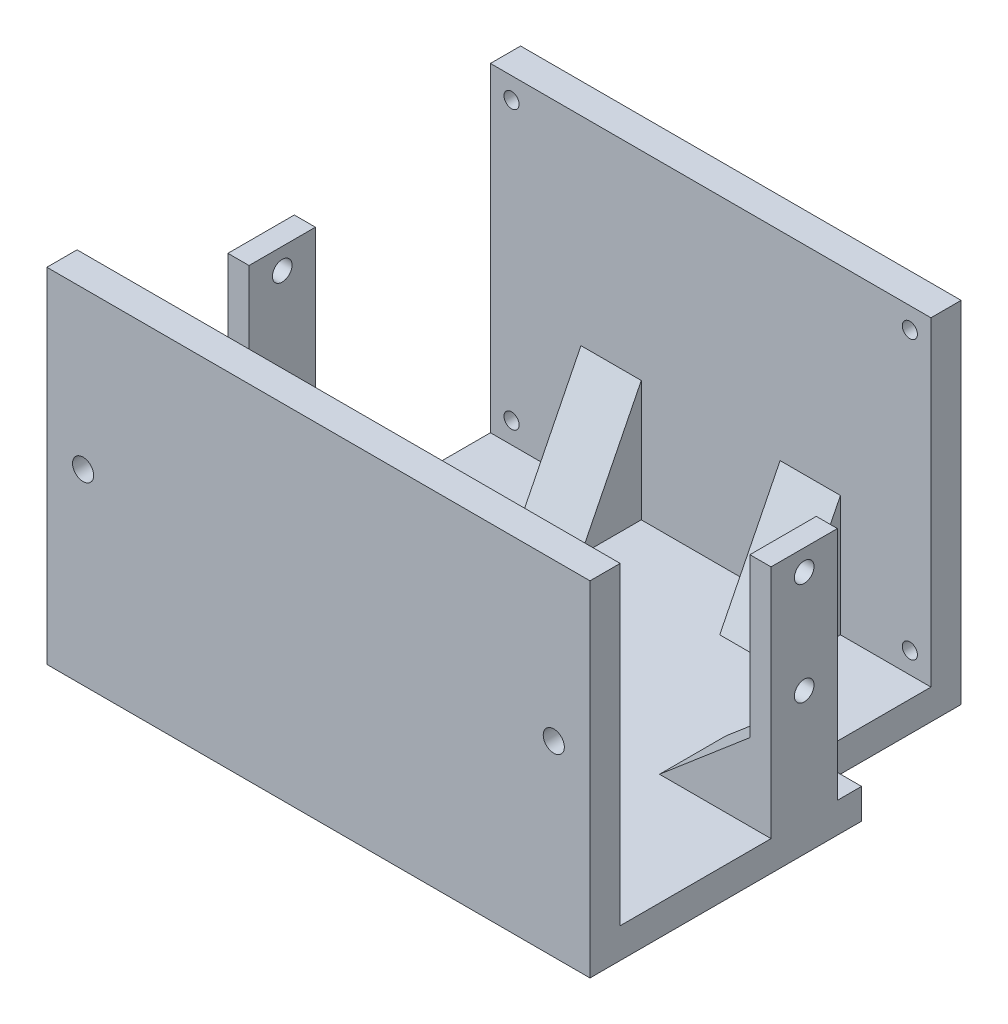
from build123d import *

# Parameters (mm, degrees)
ESTRUSIONE_ESTRUSIONE1_DEPTH = 5
SCHIZZO2_W                   = 73
SCHIZZO2_H                   = 5
ESTRUSIONE_ESTRUSIONE2_DEPTH = 53
SCHIZZO4_R                   = 1.25
TAGLIO_ESTRUSIONE1_DEPTH     = 10
SCHIZZO1_3_W                 = 3.5
SCHIZZO1_3_H                 = 11
ESTRUSIONE_ESTRUSIONE3_DEPTH = 44
SCHIZZO5_R                   = 1.625
TAGLIO_ESTRUSIONE2_DEPTH     = 113.645461515
SCHIZZO2_3_W                 = 90
SCHIZZO2_3_H                 = 5
ESTRUSIONE_ESTRUSIONE4_DEPTH = 52
SCHIZZO8_R                   = 1.75
TAGLIO_ESTRUSIONE3_DEPTH     = 99.051007134
ESTRUSIONE_ESTRUSIONE5_DEPTH = 11
ESTRUSIONE_ESTRUSIONE6_DEPTH = 5


with BuildPart() as part:
    # Schizzo1 → Estrusione-Estrusione1 (new body)
    with BuildSketch(Plane(origin=(0, 0, 0), x_dir=(1, 0, 0), z_dir=(0, 1, 0))):
        Polygon((45, 10), (36.5, 10), (36.5, 35), (-36.5, 35), (-36.5, 10), (-45, 10), (-45, 6), (-41.5, 6), (-41.5, -5), (-45, -5), (-45, -35), (45, -35), (45, -5), (41.5, -5), (41.5, 6), (45, 6), align=None)
    extrude(amount=ESTRUSIONE_ESTRUSIONE1_DEPTH)

    # Schizzo2 → Estrusione-Estrusione2 (add)
    with BuildSketch(Plane(origin=(0, 5, 0), x_dir=(1, 0, 0), z_dir=(0, 1, 0))):
        with Locations((0, 32.5)):
            Rectangle(SCHIZZO2_W, SCHIZZO2_H)
    extrude(amount=ESTRUSIONE_ESTRUSIONE2_DEPTH)

    # Schizzo4 → Taglio-Estrusione1 (cut)
    with BuildSketch(Plane(origin=(0, 0, -35), x_dir=(-1, 0, 0), z_dir=(0, 0, -1))):
        with Locations((-33, 54.5)):
            Circle(SCHIZZO4_R)
        with Locations((33, 54.5)):
            Circle(SCHIZZO4_R)
        with Locations((33, 8.5)):
            Circle(SCHIZZO4_R)
        with Locations((-33, 8.5)):
            Circle(SCHIZZO4_R)
    extrude(amount=-TAGLIO_ESTRUSIONE1_DEPTH, mode=Mode.SUBTRACT)

    # Schizzo1_3 → Estrusione-Estrusione3 (add)
    with BuildSketch(Plane(origin=(0, 0, 0), x_dir=(1, 0, 0), z_dir=(0, 1, 0))):
        with Locations((43.25, 0.5)):
            Rectangle(SCHIZZO1_3_W, SCHIZZO1_3_H)
        with Locations((-43.25, 0.5)):
            Rectangle(SCHIZZO1_3_W, SCHIZZO1_3_H)
    extrude(amount=ESTRUSIONE_ESTRUSIONE3_DEPTH)

    # Schizzo5 → Taglio-Estrusione2 (cut, through all)
    with BuildSketch(Plane.ZY.offset(45)):
        with Locations((-0.5, 40.5)):
            Circle(SCHIZZO5_R)
        with Locations((-0.5, 23.5)):
            Circle(SCHIZZO5_R)
    extrude(amount=-TAGLIO_ESTRUSIONE2_DEPTH, mode=Mode.SUBTRACT)

    # Schizzo2_3 → Estrusione-Estrusione4 (add)
    with BuildSketch(Plane(origin=(0, 5, 0), x_dir=(1, 0, 0), z_dir=(0, 1, 0))):
        with Locations((0, -32.5)):
            Rectangle(SCHIZZO2_3_W, SCHIZZO2_3_H)
    extrude(amount=ESTRUSIONE_ESTRUSIONE4_DEPTH)

    # Schizzo8 → Taglio-Estrusione3 (cut, through all)
    with BuildSketch(Plane(origin=(0, 0, 30), x_dir=(-1, 0, 0), z_dir=(0, 0, -1))):
        with Locations((-39, 31)):
            Circle(SCHIZZO8_R)
        with Locations((39, 31)):
            Circle(SCHIZZO8_R)
    extrude(amount=-TAGLIO_ESTRUSIONE3_DEPTH, mode=Mode.SUBTRACT)

    # Schizzo11 → Estrusione-Estrusione5 (add)
    with BuildSketch(Plane.XY.offset(5)):
        Polygon((-41.5, 17.747952022), (-41.5, 5), (-26.515389788, 5), align=None)
        Polygon((41.5, 5), (41.5, 17.747952022), (26.515389788, 5), align=None)
    extrude(amount=-ESTRUSIONE_ESTRUSIONE5_DEPTH)

    # Schizzo13 → Estrusione-Estrusione6 (add, symmetric)
    with BuildSketch(Plane.ZY.offset(16.5)):
        Polygon((-30, 25), (-20, 5), (-30, 5), align=None)
    estrusione_estrusione6 = extrude(amount=ESTRUSIONE_ESTRUSIONE6_DEPTH, both=True)

    # Specchia1: Estrusione-Estrusione6 across plane
    add(estrusione_estrusione6.mirror(Plane(origin=(0, 0, 0), x_dir=(0, 0, 1), z_dir=(1, 0, 0))))


solid = part.part
